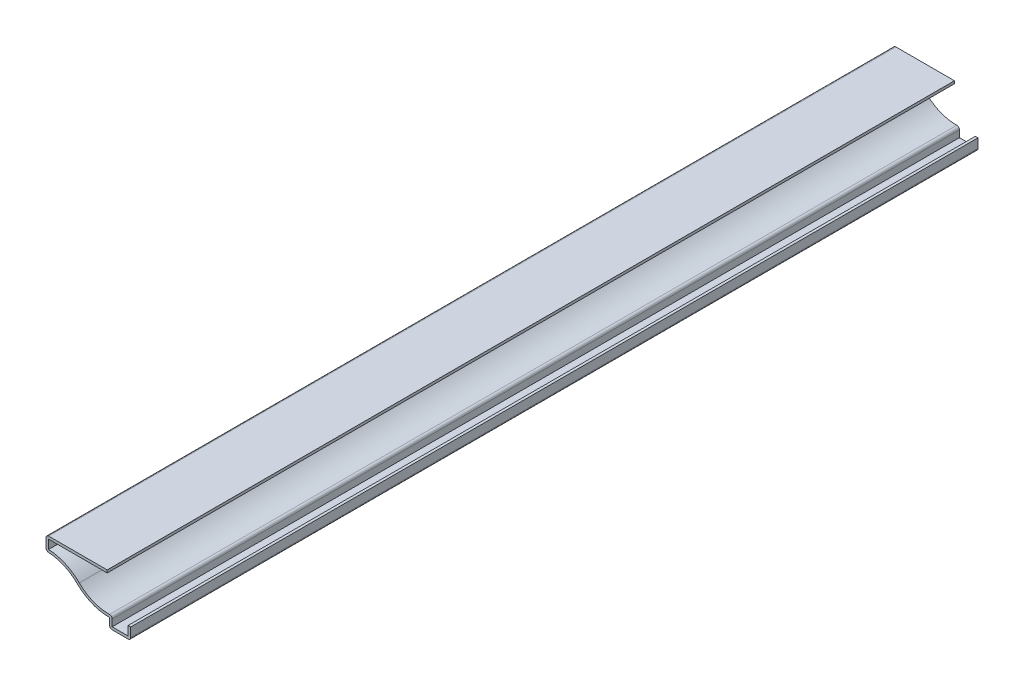
from build123d import *

# Parameters (mm, degrees)
EXTRUDE_THIN1_DEPTH = 285.75
FILLET1_R           = 0.889


with BuildPart() as part:
    # Sketch1 → Extrude-Thin1 (new body)
    with BuildSketch(Plane.XY):
        with BuildLine():
            Line((0, 3.96875), (0, 0))
            Line((0, 0), (-7.14375, 0))
            Line((-7.14375, 0), (-7.14375, 3.175))
            ThreePointArc((-7.14375, 3.175), (-12.992038746, 4.269087389), (-17.962061345, 7.539925789))
            ThreePointArc((-17.962061345, 7.539925789), (-22.83698523, 10.772017174), (-28.575, 11.90625))
            Line((-28.575, 11.90625), (-28.575, 16.66875))
            Line((-28.575, 16.66875), (-7.9375, 16.66875))
            Line((-7.9375, 16.66875), (-7.9375, 15.77975))
            Line((-7.9375, 15.77975), (-27.686, 15.77975))
            Line((-27.686, 15.77975), (-27.686, 12.770487263))
            ThreePointArc((-27.686, 12.770487263), (-22.089870787, 11.419244899), (-17.33645654, 8.171542467))
            ThreePointArc((-17.33645654, 8.171542467), (-12.238465129, 4.931402679), (-6.25475, 4.104858346))
            Line((-6.25475, 4.104858346), (-6.25475, 0.889))
            Line((-6.25475, 0.889), (-0.889, 0.889))
            Line((-0.889, 0.889), (-0.889, 3.96875))
            Line((-0.889, 3.96875), (0, 3.96875))
        make_face()
    extrude(amount=-EXTRUDE_THIN1_DEPTH)

    # Fillet1
    fillet1_edges = [part.edges().sort_by_distance(p)[0] for p in [
        (-6.25475, 4.104858346, -142.875),
        (0, 0, -142.875),
        (-7.14375, 0, -142.875),
        (-28.575, 11.90625, -142.875),
        (-28.575, 16.66875, -142.875),
    ]]
    fillet(fillet1_edges, radius=FILLET1_R)


solid = part.part
